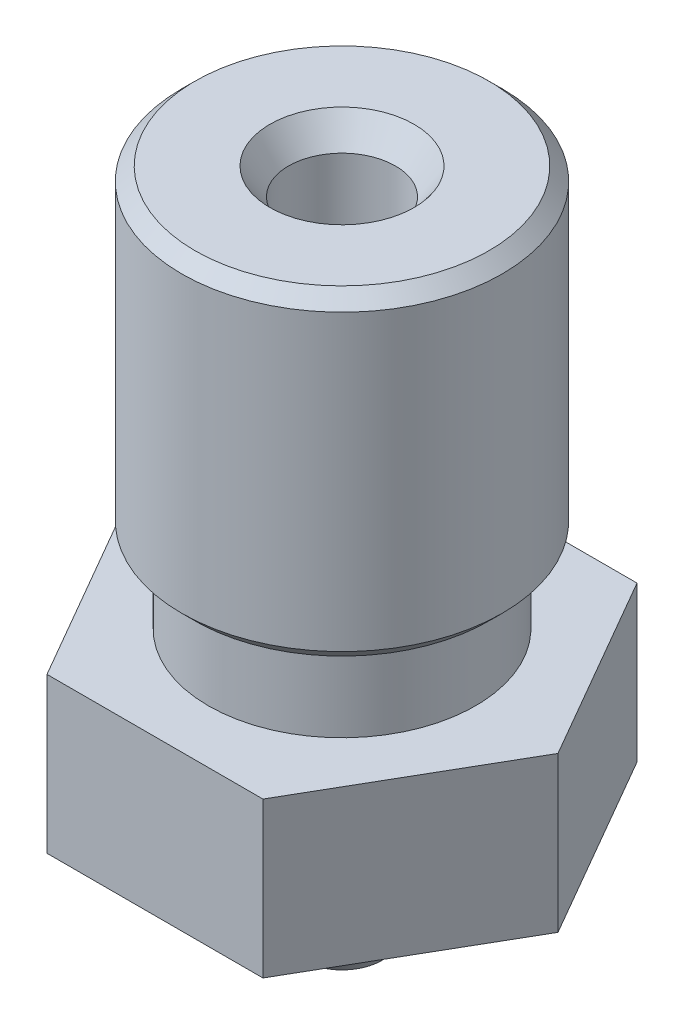
from build123d import *

# Parameters (mm, degrees)
SKETCH2_R           = 1.622490436
BOSS_EXTRUDE1_DEPTH = 2.9
CHAMFER1_SIZE       = 0.25


with BuildPart() as part:
    # Sketch1 → Revolve1 (revolve)
    with BuildSketch(Plane.XY):
        Polygon((0.3, -6.25), (0.3, -5.05), (0.995, -4.740566064), (0.995, -4.152226143), (1, -4.15), (1, 5.75), (1.350103769, 6.25), (3, 6.25), (3, 0.25), (2.5, 0.25), (2.5, -1.25), (3.5, -1.25), (3.5, -4.15), (2.22043583, -4.15), (0.75, -6.25), align=None)
    revolve(axis=Axis((0, -6.25, 0), (0, 1, 0)))

    # Sketch2 → Boss-Extrude1 (add)
    with BuildSketch(Plane.XZ.offset(4.15)):
        Polygon((2.020725942, 3.5), (-2.020725942, 3.5), (-4.041451884, 0), (-2.020725942, -3.5), (2.020725942, -3.5), (4.041451884, 0), align=None)
        Circle(SKETCH2_R, mode=Mode.SUBTRACT)
    extrude(amount=-BOSS_EXTRUDE1_DEPTH)

    # Chamfer1
    chamfer1_edges = [part.edges().sort_by_distance(p)[0] for p in [
        (-3, 0.25, 0),
        (-3, 6.25, 0),
    ]]
    chamfer(chamfer1_edges, length=CHAMFER1_SIZE)


solid = part.part
